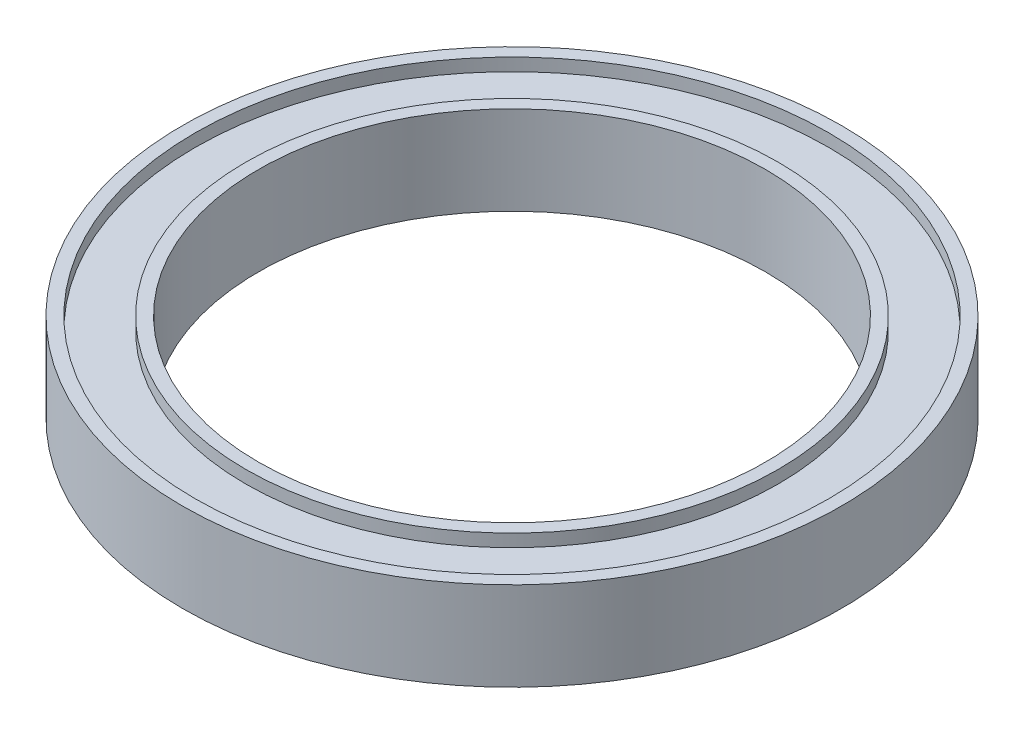
from build123d import *

# Parameters (mm, degrees)
CROQUIS1_R              = 26
CROQUIS1_R_2            = 20
SALIENTE_EXTRUIR1_DEPTH = 3.5
CROQUIS2_R              = 25
CROQUIS2_R_2            = 21
CORTAR_EXTRUIR1_DEPTH   = 1


with BuildPart() as part:
    # Croquis1 → Saliente-Extruir1 (new body, symmetric)
    with BuildSketch(Plane(origin=(0, 0, 0), x_dir=(1, 0, 0), z_dir=(0, 1, 0))):
        Circle(CROQUIS1_R)
        Circle(CROQUIS1_R_2, mode=Mode.SUBTRACT)
    extrude(amount=SALIENTE_EXTRUIR1_DEPTH, both=True)

    # Croquis2 → Cortar-Extruir1 (cut)
    with BuildSketch(Plane(origin=(0, 3.5, 0), x_dir=(1, 0, 0), z_dir=(0, 1, 0))):
        Circle(CROQUIS2_R)
        Circle(CROQUIS2_R_2, mode=Mode.SUBTRACT)
    cortar_extruir1 = extrude(amount=-CORTAR_EXTRUIR1_DEPTH, mode=Mode.SUBTRACT)

    # Simetría1: Cortar-Extruir1 across plane
    add(cortar_extruir1.mirror(Plane.ZX), mode=Mode.SUBTRACT)


solid = part.part
